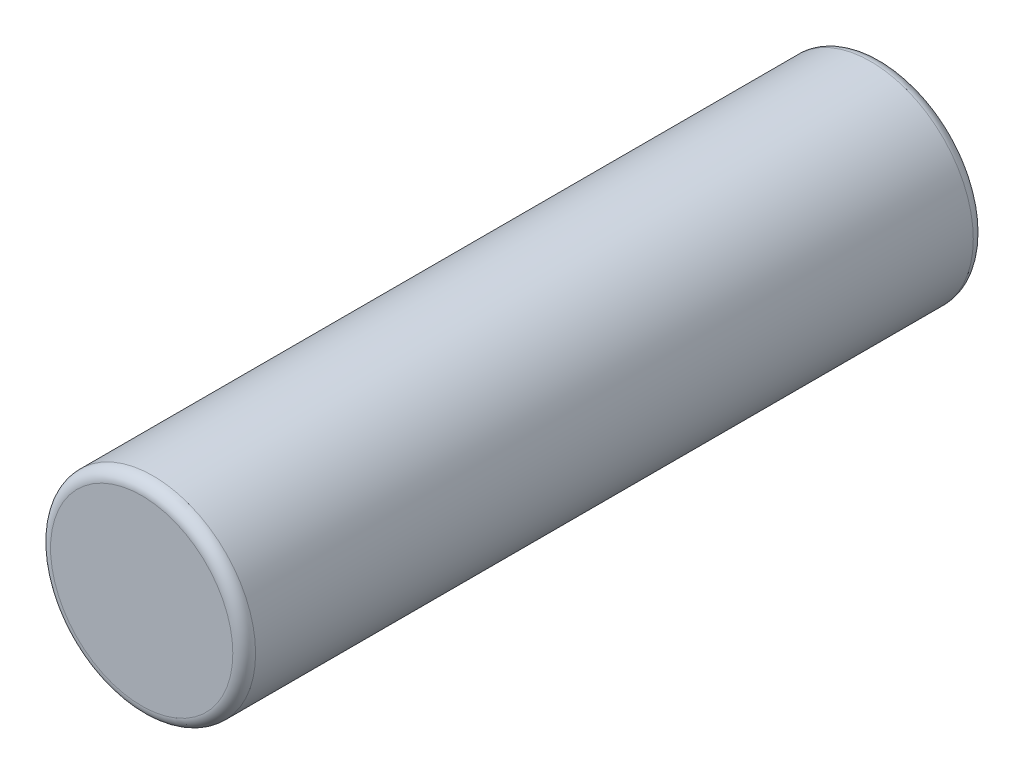
from build123d import *

# Parameters (mm, degrees)
SKIZZE1_R                       = 9
AUFSATZ_LINEAR_AUSTRAGEN1_DEPTH = 65
VERRUNDUNG1_R                   = 1


with BuildPart() as part:
    # Skizze1 → Aufsatz-Linear austragen1 (new body)
    with BuildSketch(Plane.XY):
        Circle(SKIZZE1_R)
    extrude(amount=AUFSATZ_LINEAR_AUSTRAGEN1_DEPTH)

    # Verrundung1
    verrundung1_edges = [part.edges().sort_by_distance(p)[0] for p in [
        (-9, 0, 0),
        (-9, 0, 65),
    ]]
    fillet(verrundung1_edges, radius=VERRUNDUNG1_R)


solid = part.part
